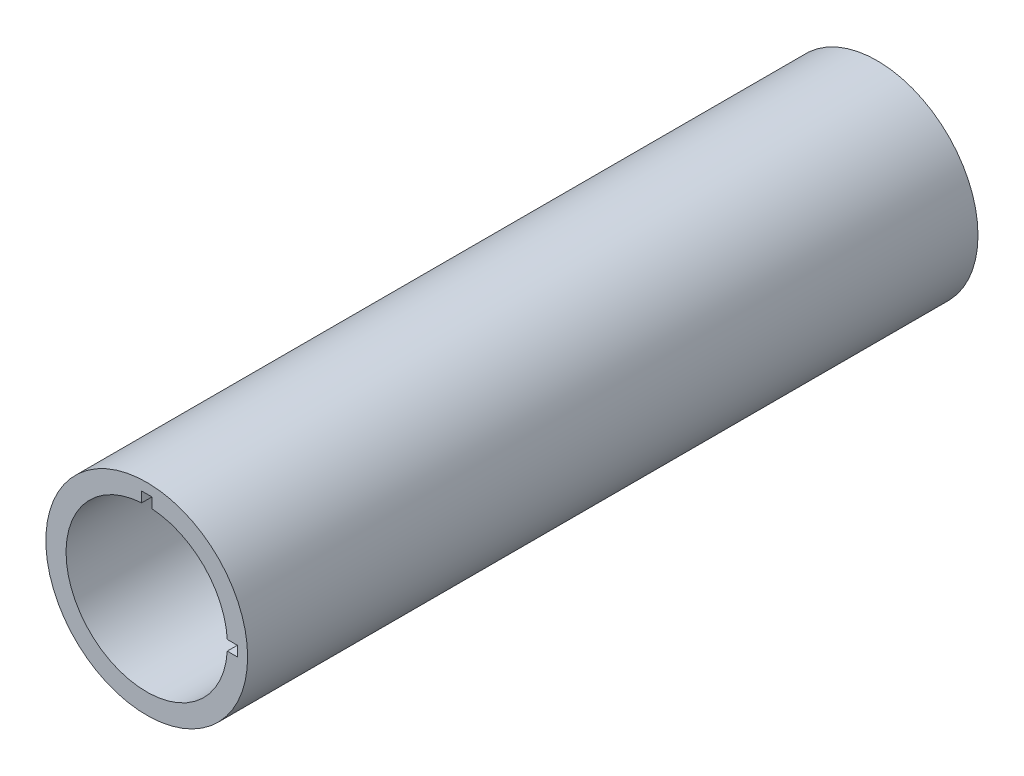
from build123d import *

# Parameters (mm, degrees)
SKETCH1_R           = 25
SKETCH1_R_2         = 20
BOSS_EXTRUDE1_DEPTH = 181
SKETCH5_W           = 2.5
SKETCH5_H           = 30
CUT_EXTRUDE2_DEPTH  = 6
CIRPATTERN8_COUNT   = 2
CIRPATTERN8_ANGLE   = 90


with BuildPart() as part:
    # Sketch1 → Boss-Extrude1 (new body)
    with BuildSketch(Plane.XY):
        Circle(SKETCH1_R)
        Circle(SKETCH1_R_2, mode=Mode.SUBTRACT)
    extrude(amount=BOSS_EXTRUDE1_DEPTH)

    # Sketch5 → Cut-Extrude2 (cut)
    with BuildSketch(Plane(origin=(0, 22.5, 0), x_dir=(-1, 0, 0), z_dir=(0, 1, 0))):
        with Locations((0, 166.230203819)):
            Rectangle(SKETCH5_W, SKETCH5_H)
    cut_extrude2 = extrude(amount=-CUT_EXTRUDE2_DEPTH, mode=Mode.SUBTRACT)

    # CirPattern8: Cut-Extrude2 ×2 about axis
    cirpattern8_axis = Axis((0, 0, 0), (0, 0, -1))
    for i in range(1, CIRPATTERN8_COUNT):
        add(cut_extrude2.rotate(cirpattern8_axis, i * CIRPATTERN8_ANGLE / (CIRPATTERN8_COUNT - 1)), mode=Mode.SUBTRACT)


solid = part.part
